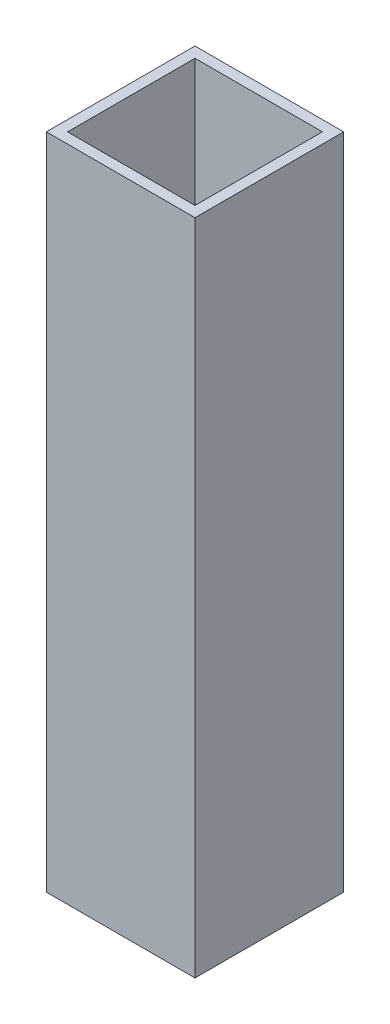
from build123d import *

# Parameters (mm, degrees)
SKETCH1_W           = 44.45
SKETCH1_H           = 44.45
SKETCH1_W_2         = 38.1
SKETCH1_H_2         = 38.1
BOSS_EXTRUDE1_DEPTH = 196.85


with BuildPart() as part:
    # Sketch1 → Boss-Extrude1 (new body)
    with BuildSketch(Plane(origin=(0, 0, 0), x_dir=(1, 0, 0), z_dir=(0, 1, 0))):
        with Locations((22.225, 22.225)):
            Rectangle(SKETCH1_W, SKETCH1_H)
        with Locations((22.225, 22.225)):
            Rectangle(SKETCH1_W_2, SKETCH1_H_2, mode=Mode.SUBTRACT)
    extrude(amount=BOSS_EXTRUDE1_DEPTH)


solid = part.part
